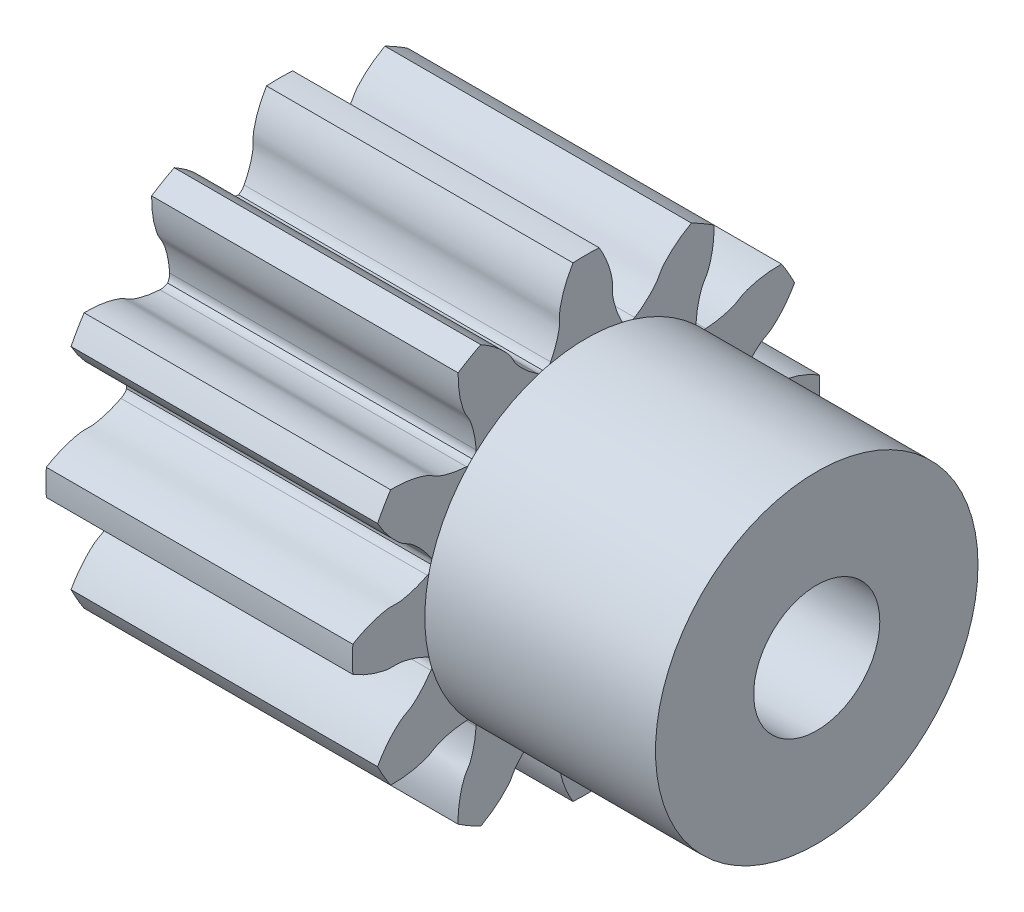
from build123d import *

# Parameters (mm, degrees)
SKETCH2_R      = 1.5
EXTRUDE1_DEPTH = 7.2898
SKETCH3_R      = 3.8354
SKETCH3_R_2    = 1.5
EXTRUDE2_DEPTH = 5.4864


with BuildPart() as part:
    # Sketch2 → Extrude1 (new body)
    with BuildSketch(Plane(origin=(0, 0, 0), x_dir=(0, 0, -1), z_dir=(1, 0, 0))):
        with BuildLine():
            ThreePointArc((-2.663120489, -2.663120489), (-2.750995667, -2.62511387), (-2.84628134, -2.615776294))
            add(Edge.make_bspline(
                [(-4.648816404, -3.043093837), (-4.614073522, -3.04349562), (-4.544568705, -3.043210814), (-4.440389461, -3.03921779), (-4.33642338, -3.031358347), (-4.232893645, -3.01896386), (-4.130045907, -3.001804641), (-4.028117704, -2.979814706), (-3.927423519, -2.952725802), (-3.827984631, -2.92152287), (-3.731196978, -2.881880043), (-3.642376214, -2.827118867), (-3.553555449, -2.772357691), (-3.456767797, -2.732714864), (-3.357328909, -2.701511932), (-3.256634724, -2.674423028), (-3.154706521, -2.652433093), (-3.051858782, -2.635273874), (-2.948976716, -2.622956925), (-2.880319624, -2.6177384), (-2.84628134, -2.615776294)],
                knots=[0.009804155, 0.009804155, 0.009804155, 0.009804155, 0.064334183, 0.118864103, 0.173393087, 0.227921379, 0.282449292, 0.336977028, 0.391504536, 0.446030976, 0.500535771, 0.555042104, 0.609548437, 0.664053231, 0.718579671, 0.773107179, 0.827634915, 0.882162828, 0.93669112, 0.990196737, 0.990196737, 0.990196737, 0.990196737], degree=3, weights=[1, 1, 1, 1, 1, 1, 1, 1, 1, 1, 1, 1, 1, 1, 1, 1, 1, 1, 1, 1, 1]))
            ThreePointArc((-4.648816404, -3.043093837), (-4.81185365, -2.778125), (-4.959804771, -2.504446185))
            add(Edge.make_bspline(
                [(-3.688469392, -1.1570638), (-3.707187767, -1.185560765), (-3.746035688, -1.242410288), (-3.808143512, -1.325350297), (-3.8744277, -1.405839442), (-3.944435644, -1.483116888), (-4.018242417, -1.556776158), (-4.094984392, -1.627291295), (-4.177709914, -1.691290447), (-4.269544865, -1.740830898), (-4.361379817, -1.790371348), (-4.444105339, -1.8543705), (-4.520847314, -1.924885638), (-4.594654086, -1.998544908), (-4.66466203, -2.075822354), (-4.730946218, -2.156311498), (-4.793445026, -2.239773635), (-4.852234544, -2.325881181), (-4.907782226, -2.414106541), (-4.942781284, -2.474157075), (-4.959804771, -2.504446185)],
                knots=[0.009803389, 0.009803389, 0.009803389, 0.009803389, 0.063309017, 0.117837321, 0.172365245, 0.226892992, 0.281420511, 0.335946963, 0.390451768, 0.444958113, 0.499464457, 0.553969263, 0.608495715, 0.663023233, 0.717550981, 0.772078905, 0.826607208, 0.881136204, 0.935666135, 0.990196174, 0.990196174, 0.990196174, 0.990196174], degree=3, weights=[1, 1, 1, 1, 1, 1, 1, 1, 1, 1, 1, 1, 1, 1, 1, 1, 1, 1, 1, 1, 1]))
            ThreePointArc((-3.688469392, -1.1570638), (-3.648913133, -1.069875198), (-3.637890241, -0.974769752))
            ThreePointArc((-3.637890241, -0.974769752), (-3.694989068, -0.897917466), (-3.772840094, -0.842188051))
            add(Edge.make_bspline(
                [(-5.547540022, -0.310988367), (-5.517652695, -0.328707763), (-5.457317354, -0.363213521), (-5.365098971, -0.411845083), (-5.271131982, -0.457021646), (-5.175275358, -0.498052573), (-5.077626995, -0.534616123), (-4.978359614, -0.566536382), (-4.877611439, -0.593423795), (-4.775893371, -0.616120708), (-4.672251391, -0.630182838), (-4.567949765, -0.627168651), (-4.463648138, -0.624154464), (-4.360006159, -0.638216595), (-4.25828809, -0.660913508), (-4.157539915, -0.687800921), (-4.058272535, -0.71972118), (-3.960624171, -0.75628473), (-3.865367214, -0.797058973), (-3.803299165, -0.826868143), (-3.772840094, -0.842188051)],
                knots=[0.009804155, 0.009804155, 0.009804155, 0.009804155, 0.064334183, 0.118864103, 0.173393087, 0.227921379, 0.282449292, 0.336977028, 0.391504536, 0.446030976, 0.500535771, 0.555042104, 0.609548437, 0.664053231, 0.718579671, 0.773107179, 0.827634915, 0.882162828, 0.93669112, 0.990196737, 0.990196737, 0.990196737, 0.990196737], degree=3, weights=[1, 1, 1, 1, 1, 1, 1, 1, 1, 1, 1, 1, 1, 1, 1, 1, 1, 1, 1, 1, 1]))
            ThreePointArc((-5.547540022, -0.310988367), (-5.55625, 0), (-5.547540022, 0.310988367))
            add(Edge.make_bspline(
                [(-3.772840094, 0.842188051), (-3.803299165, 0.826868143), (-3.865367214, 0.797058973), (-3.960624171, 0.75628473), (-4.058272535, 0.71972118), (-4.157539915, 0.687800921), (-4.25828809, 0.660913508), (-4.360006159, 0.638216595), (-4.463648138, 0.624154464), (-4.567949765, 0.627168651), (-4.672251391, 0.630182838), (-4.775893371, 0.616120708), (-4.877611439, 0.593423795), (-4.978359614, 0.566536382), (-5.077626995, 0.534616123), (-5.175275358, 0.498052573), (-5.271131982, 0.457021646), (-5.365098971, 0.411845083), (-5.457317354, 0.363213521), (-5.517652695, 0.328707763), (-5.547540022, 0.310988367)],
                knots=[0.009803389, 0.009803389, 0.009803389, 0.009803389, 0.063309017, 0.117837321, 0.172365245, 0.226892992, 0.281420511, 0.335946963, 0.390451768, 0.444958113, 0.499464457, 0.553969263, 0.608495715, 0.663023233, 0.717550981, 0.772078905, 0.826607208, 0.881136204, 0.935666135, 0.990196174, 0.990196174, 0.990196174, 0.990196174], degree=3, weights=[1, 1, 1, 1, 1, 1, 1, 1, 1, 1, 1, 1, 1, 1, 1, 1, 1, 1, 1, 1, 1]))
            ThreePointArc((-3.772840094, 0.842188051), (-3.694989068, 0.897917466), (-3.637890241, 0.974769752))
            ThreePointArc((-3.637890241, 0.974769752), (-3.648913133, 1.069875198), (-3.688469392, 1.1570638))
            add(Edge.make_bspline(
                [(-4.959804771, 2.504446185), (-4.942781284, 2.474157075), (-4.907782226, 2.414106541), (-4.852234544, 2.325881181), (-4.793445026, 2.239773635), (-4.730946218, 2.156311498), (-4.66466203, 2.075822354), (-4.594654086, 1.998544908), (-4.520847314, 1.924885638), (-4.444105339, 1.8543705), (-4.361379817, 1.790371348), (-4.269544865, 1.740830898), (-4.177709914, 1.691290447), (-4.094984392, 1.627291295), (-4.018242417, 1.556776158), (-3.944435644, 1.483116888), (-3.8744277, 1.405839442), (-3.808143512, 1.325350297), (-3.746035688, 1.242410288), (-3.707187767, 1.185560765), (-3.688469392, 1.1570638)],
                knots=[0.009804155, 0.009804155, 0.009804155, 0.009804155, 0.064334183, 0.118864103, 0.173393087, 0.227921379, 0.282449292, 0.336977028, 0.391504536, 0.446030976, 0.500535771, 0.555042104, 0.609548437, 0.664053231, 0.718579671, 0.773107179, 0.827634915, 0.882162828, 0.93669112, 0.990196737, 0.990196737, 0.990196737, 0.990196737], degree=3, weights=[1, 1, 1, 1, 1, 1, 1, 1, 1, 1, 1, 1, 1, 1, 1, 1, 1, 1, 1, 1, 1]))
            ThreePointArc((-4.959804771, 2.504446185), (-4.81185365, 2.778125), (-4.648816404, 3.043093837))
            add(Edge.make_bspline(
                [(-2.84628134, 2.615776294), (-2.880319624, 2.6177384), (-2.948976716, 2.622956925), (-3.051858782, 2.635273874), (-3.154706521, 2.652433093), (-3.256634724, 2.674423028), (-3.357328909, 2.701511932), (-3.456767797, 2.732714864), (-3.553555449, 2.772357691), (-3.642376214, 2.827118867), (-3.731196978, 2.881880043), (-3.827984631, 2.92152287), (-3.927423519, 2.952725802), (-4.028117704, 2.979814706), (-4.130045907, 3.001804641), (-4.232893645, 3.01896386), (-4.33642338, 3.031358347), (-4.440389461, 3.03921779), (-4.544568705, 3.043210814), (-4.614073522, 3.04349562), (-4.648816404, 3.043093837)],
                knots=[0.009803389, 0.009803389, 0.009803389, 0.009803389, 0.063309017, 0.117837321, 0.172365245, 0.226892992, 0.281420511, 0.335946963, 0.390451768, 0.444958113, 0.499464457, 0.553969263, 0.608495715, 0.663023233, 0.717550981, 0.772078905, 0.826607208, 0.881136204, 0.935666135, 0.990196174, 0.990196174, 0.990196174, 0.990196174], degree=3, weights=[1, 1, 1, 1, 1, 1, 1, 1, 1, 1, 1, 1, 1, 1, 1, 1, 1, 1, 1, 1, 1]))
            ThreePointArc((-2.84628134, 2.615776294), (-2.750995667, 2.62511387), (-2.663120489, 2.663120489))
            ThreePointArc((-2.663120489, 2.663120489), (-2.62511387, 2.750995667), (-2.615776294, 2.84628134))
            add(Edge.make_bspline(
                [(-3.043093837, 4.648816404), (-3.04349562, 4.614073522), (-3.043210814, 4.544568705), (-3.03921779, 4.440389461), (-3.031358347, 4.33642338), (-3.01896386, 4.232893645), (-3.001804641, 4.130045907), (-2.979814706, 4.028117704), (-2.952725802, 3.927423519), (-2.92152287, 3.827984631), (-2.881880043, 3.731196978), (-2.827118867, 3.642376214), (-2.772357691, 3.553555449), (-2.732714864, 3.456767797), (-2.701511932, 3.357328909), (-2.674423028, 3.256634724), (-2.652433093, 3.154706521), (-2.635273874, 3.051858782), (-2.622956925, 2.948976716), (-2.6177384, 2.880319624), (-2.615776294, 2.84628134)],
                knots=[0.009804155, 0.009804155, 0.009804155, 0.009804155, 0.064334183, 0.118864103, 0.173393087, 0.227921379, 0.282449292, 0.336977028, 0.391504536, 0.446030976, 0.500535771, 0.555042104, 0.609548437, 0.664053231, 0.718579671, 0.773107179, 0.827634915, 0.882162828, 0.93669112, 0.990196737, 0.990196737, 0.990196737, 0.990196737], degree=3, weights=[1, 1, 1, 1, 1, 1, 1, 1, 1, 1, 1, 1, 1, 1, 1, 1, 1, 1, 1, 1, 1]))
            ThreePointArc((-3.043093837, 4.648816404), (-2.778125, 4.81185365), (-2.504446185, 4.959804771))
            add(Edge.make_bspline(
                [(-1.1570638, 3.688469392), (-1.185560765, 3.707187767), (-1.242410288, 3.746035688), (-1.325350297, 3.808143512), (-1.405839442, 3.8744277), (-1.483116888, 3.944435644), (-1.556776158, 4.018242417), (-1.627291295, 4.094984392), (-1.691290447, 4.177709914), (-1.740830898, 4.269544865), (-1.790371348, 4.361379817), (-1.8543705, 4.444105339), (-1.924885638, 4.520847314), (-1.998544908, 4.594654086), (-2.075822354, 4.66466203), (-2.156311498, 4.730946218), (-2.239773635, 4.793445026), (-2.325881181, 4.852234544), (-2.414106541, 4.907782226), (-2.474157075, 4.942781284), (-2.504446185, 4.959804771)],
                knots=[0.009803389, 0.009803389, 0.009803389, 0.009803389, 0.063309017, 0.117837321, 0.172365245, 0.226892992, 0.281420511, 0.335946963, 0.390451768, 0.444958113, 0.499464457, 0.553969263, 0.608495715, 0.663023233, 0.717550981, 0.772078905, 0.826607208, 0.881136204, 0.935666135, 0.990196174, 0.990196174, 0.990196174, 0.990196174], degree=3, weights=[1, 1, 1, 1, 1, 1, 1, 1, 1, 1, 1, 1, 1, 1, 1, 1, 1, 1, 1, 1, 1]))
            ThreePointArc((-1.1570638, 3.688469392), (-1.069875198, 3.648913133), (-0.974769752, 3.637890241))
            ThreePointArc((-0.974769752, 3.637890241), (-0.897917466, 3.694989068), (-0.842188051, 3.772840094))
            add(Edge.make_bspline(
                [(-0.310988367, 5.547540022), (-0.328707763, 5.517652695), (-0.363213521, 5.457317354), (-0.411845083, 5.365098971), (-0.457021646, 5.271131982), (-0.498052573, 5.175275358), (-0.534616123, 5.077626995), (-0.566536382, 4.978359614), (-0.593423795, 4.877611439), (-0.616120708, 4.775893371), (-0.630182838, 4.672251391), (-0.627168651, 4.567949765), (-0.624154464, 4.463648138), (-0.638216595, 4.360006159), (-0.660913508, 4.25828809), (-0.687800921, 4.157539915), (-0.71972118, 4.058272535), (-0.75628473, 3.960624171), (-0.797058973, 3.865367214), (-0.826868143, 3.803299165), (-0.842188051, 3.772840094)],
                knots=[0.009804155, 0.009804155, 0.009804155, 0.009804155, 0.064334183, 0.118864103, 0.173393087, 0.227921379, 0.282449292, 0.336977028, 0.391504536, 0.446030976, 0.500535771, 0.555042104, 0.609548437, 0.664053231, 0.718579671, 0.773107179, 0.827634915, 0.882162828, 0.93669112, 0.990196737, 0.990196737, 0.990196737, 0.990196737], degree=3, weights=[1, 1, 1, 1, 1, 1, 1, 1, 1, 1, 1, 1, 1, 1, 1, 1, 1, 1, 1, 1, 1]))
            ThreePointArc((-0.310988367, 5.547540022), (0, 5.55625), (0.310988367, 5.547540022))
            add(Edge.make_bspline(
                [(0.842188051, 3.772840094), (0.826868143, 3.803299165), (0.797058973, 3.865367214), (0.75628473, 3.960624171), (0.71972118, 4.058272535), (0.687800921, 4.157539915), (0.660913508, 4.25828809), (0.638216595, 4.360006159), (0.624154464, 4.463648138), (0.627168651, 4.567949765), (0.630182838, 4.672251391), (0.616120708, 4.775893371), (0.593423795, 4.877611439), (0.566536382, 4.978359614), (0.534616123, 5.077626995), (0.498052573, 5.175275358), (0.457021646, 5.271131982), (0.411845083, 5.365098971), (0.363213521, 5.457317354), (0.328707763, 5.517652695), (0.310988367, 5.547540022)],
                knots=[0.009803389, 0.009803389, 0.009803389, 0.009803389, 0.063309017, 0.117837321, 0.172365245, 0.226892992, 0.281420511, 0.335946963, 0.390451768, 0.444958113, 0.499464457, 0.553969263, 0.608495715, 0.663023233, 0.717550981, 0.772078905, 0.826607208, 0.881136204, 0.935666135, 0.990196174, 0.990196174, 0.990196174, 0.990196174], degree=3, weights=[1, 1, 1, 1, 1, 1, 1, 1, 1, 1, 1, 1, 1, 1, 1, 1, 1, 1, 1, 1, 1]))
            ThreePointArc((0.842188051, 3.772840094), (0.897917466, 3.694989068), (0.974769752, 3.637890241))
            ThreePointArc((0.974769752, 3.637890241), (1.069875198, 3.648913133), (1.1570638, 3.688469392))
            add(Edge.make_bspline(
                [(2.504446185, 4.959804771), (2.474157075, 4.942781284), (2.414106541, 4.907782226), (2.325881181, 4.852234544), (2.239773635, 4.793445026), (2.156311498, 4.730946218), (2.075822354, 4.66466203), (1.998544908, 4.594654086), (1.924885638, 4.520847314), (1.8543705, 4.444105339), (1.790371348, 4.361379817), (1.740830898, 4.269544865), (1.691290447, 4.177709914), (1.627291295, 4.094984392), (1.556776158, 4.018242417), (1.483116888, 3.944435644), (1.405839442, 3.8744277), (1.325350297, 3.808143512), (1.242410288, 3.746035688), (1.185560765, 3.707187767), (1.1570638, 3.688469392)],
                knots=[0.009804155, 0.009804155, 0.009804155, 0.009804155, 0.064334183, 0.118864103, 0.173393087, 0.227921379, 0.282449292, 0.336977028, 0.391504536, 0.446030976, 0.500535771, 0.555042104, 0.609548437, 0.664053231, 0.718579671, 0.773107179, 0.827634915, 0.882162828, 0.93669112, 0.990196737, 0.990196737, 0.990196737, 0.990196737], degree=3, weights=[1, 1, 1, 1, 1, 1, 1, 1, 1, 1, 1, 1, 1, 1, 1, 1, 1, 1, 1, 1, 1]))
            ThreePointArc((2.504446185, 4.959804771), (2.778125, 4.81185365), (3.043093837, 4.648816404))
            add(Edge.make_bspline(
                [(2.615776294, 2.84628134), (2.6177384, 2.880319624), (2.622956925, 2.948976716), (2.635273874, 3.051858782), (2.652433093, 3.154706521), (2.674423028, 3.256634724), (2.701511932, 3.357328909), (2.732714864, 3.456767797), (2.772357691, 3.553555449), (2.827118867, 3.642376214), (2.881880043, 3.731196978), (2.92152287, 3.827984631), (2.952725802, 3.927423519), (2.979814706, 4.028117704), (3.001804641, 4.130045907), (3.01896386, 4.232893645), (3.031358347, 4.33642338), (3.03921779, 4.440389461), (3.043210814, 4.544568705), (3.04349562, 4.614073522), (3.043093837, 4.648816404)],
                knots=[0.009803389, 0.009803389, 0.009803389, 0.009803389, 0.063309017, 0.117837321, 0.172365245, 0.226892992, 0.281420511, 0.335946963, 0.390451768, 0.444958113, 0.499464457, 0.553969263, 0.608495715, 0.663023233, 0.717550981, 0.772078905, 0.826607208, 0.881136204, 0.935666135, 0.990196174, 0.990196174, 0.990196174, 0.990196174], degree=3, weights=[1, 1, 1, 1, 1, 1, 1, 1, 1, 1, 1, 1, 1, 1, 1, 1, 1, 1, 1, 1, 1]))
            ThreePointArc((2.615776294, 2.84628134), (2.62511387, 2.750995667), (2.663120489, 2.663120489))
            ThreePointArc((2.663120489, 2.663120489), (2.750995667, 2.62511387), (2.84628134, 2.615776294))
            add(Edge.make_bspline(
                [(4.648816404, 3.043093837), (4.614073522, 3.04349562), (4.544568705, 3.043210814), (4.440389461, 3.03921779), (4.33642338, 3.031358347), (4.232893645, 3.01896386), (4.130045907, 3.001804641), (4.028117704, 2.979814706), (3.927423519, 2.952725802), (3.827984631, 2.92152287), (3.731196978, 2.881880043), (3.642376214, 2.827118867), (3.553555449, 2.772357691), (3.456767797, 2.732714864), (3.357328909, 2.701511932), (3.256634724, 2.674423028), (3.154706521, 2.652433093), (3.051858782, 2.635273874), (2.948976716, 2.622956925), (2.880319624, 2.6177384), (2.84628134, 2.615776294)],
                knots=[0.009804155, 0.009804155, 0.009804155, 0.009804155, 0.064334183, 0.118864103, 0.173393087, 0.227921379, 0.282449292, 0.336977028, 0.391504536, 0.446030976, 0.500535771, 0.555042104, 0.609548437, 0.664053231, 0.718579671, 0.773107179, 0.827634915, 0.882162828, 0.93669112, 0.990196737, 0.990196737, 0.990196737, 0.990196737], degree=3, weights=[1, 1, 1, 1, 1, 1, 1, 1, 1, 1, 1, 1, 1, 1, 1, 1, 1, 1, 1, 1, 1]))
            ThreePointArc((4.648816404, 3.043093837), (4.81185365, 2.778125), (4.959804771, 2.504446185))
            add(Edge.make_bspline(
                [(3.688469392, 1.1570638), (3.707187767, 1.185560765), (3.746035688, 1.242410288), (3.808143512, 1.325350297), (3.8744277, 1.405839442), (3.944435644, 1.483116888), (4.018242417, 1.556776158), (4.094984392, 1.627291295), (4.177709914, 1.691290447), (4.269544865, 1.740830898), (4.361379817, 1.790371348), (4.444105339, 1.8543705), (4.520847314, 1.924885638), (4.594654086, 1.998544908), (4.66466203, 2.075822354), (4.730946218, 2.156311498), (4.793445026, 2.239773635), (4.852234544, 2.325881181), (4.907782226, 2.414106541), (4.942781284, 2.474157075), (4.959804771, 2.504446185)],
                knots=[0.009803389, 0.009803389, 0.009803389, 0.009803389, 0.063309017, 0.117837321, 0.172365245, 0.226892992, 0.281420511, 0.335946963, 0.390451768, 0.444958113, 0.499464457, 0.553969263, 0.608495715, 0.663023233, 0.717550981, 0.772078905, 0.826607208, 0.881136204, 0.935666135, 0.990196174, 0.990196174, 0.990196174, 0.990196174], degree=3, weights=[1, 1, 1, 1, 1, 1, 1, 1, 1, 1, 1, 1, 1, 1, 1, 1, 1, 1, 1, 1, 1]))
            ThreePointArc((3.688469392, 1.1570638), (3.648913133, 1.069875198), (3.637890241, 0.974769752))
            ThreePointArc((3.637890241, 0.974769752), (3.694989068, 0.897917466), (3.772840094, 0.842188051))
            add(Edge.make_bspline(
                [(5.547540022, 0.310988367), (5.517652695, 0.328707763), (5.457317354, 0.363213521), (5.365098971, 0.411845083), (5.271131982, 0.457021646), (5.175275358, 0.498052573), (5.077626995, 0.534616123), (4.978359614, 0.566536382), (4.877611439, 0.593423795), (4.775893371, 0.616120708), (4.672251391, 0.630182838), (4.567949765, 0.627168651), (4.463648138, 0.624154464), (4.360006159, 0.638216595), (4.25828809, 0.660913508), (4.157539915, 0.687800921), (4.058272535, 0.71972118), (3.960624171, 0.75628473), (3.865367214, 0.797058973), (3.803299165, 0.826868143), (3.772840094, 0.842188051)],
                knots=[0.009804155, 0.009804155, 0.009804155, 0.009804155, 0.064334183, 0.118864103, 0.173393087, 0.227921379, 0.282449292, 0.336977028, 0.391504536, 0.446030976, 0.500535771, 0.555042104, 0.609548437, 0.664053231, 0.718579671, 0.773107179, 0.827634915, 0.882162828, 0.93669112, 0.990196737, 0.990196737, 0.990196737, 0.990196737], degree=3, weights=[1, 1, 1, 1, 1, 1, 1, 1, 1, 1, 1, 1, 1, 1, 1, 1, 1, 1, 1, 1, 1]))
            ThreePointArc((5.547540022, 0.310988367), (5.55625, 0), (5.547540022, -0.310988367))
            add(Edge.make_bspline(
                [(3.772840094, -0.842188051), (3.803299165, -0.826868143), (3.865367214, -0.797058973), (3.960624171, -0.75628473), (4.058272535, -0.71972118), (4.157539915, -0.687800921), (4.25828809, -0.660913508), (4.360006159, -0.638216595), (4.463648138, -0.624154464), (4.567949765, -0.627168651), (4.672251391, -0.630182838), (4.775893371, -0.616120708), (4.877611439, -0.593423795), (4.978359614, -0.566536382), (5.077626995, -0.534616123), (5.175275358, -0.498052573), (5.271131982, -0.457021646), (5.365098971, -0.411845083), (5.457317354, -0.363213521), (5.517652695, -0.328707763), (5.547540022, -0.310988367)],
                knots=[0.009803389, 0.009803389, 0.009803389, 0.009803389, 0.063309017, 0.117837321, 0.172365245, 0.226892992, 0.281420511, 0.335946963, 0.390451768, 0.444958113, 0.499464457, 0.553969263, 0.608495715, 0.663023233, 0.717550981, 0.772078905, 0.826607208, 0.881136204, 0.935666135, 0.990196174, 0.990196174, 0.990196174, 0.990196174], degree=3, weights=[1, 1, 1, 1, 1, 1, 1, 1, 1, 1, 1, 1, 1, 1, 1, 1, 1, 1, 1, 1, 1]))
            ThreePointArc((3.772840094, -0.842188051), (3.694989068, -0.897917466), (3.637890241, -0.974769752))
            ThreePointArc((3.637890241, -0.974769752), (3.648913133, -1.069875198), (3.688469392, -1.1570638))
            add(Edge.make_bspline(
                [(4.959804771, -2.504446185), (4.942781284, -2.474157075), (4.907782226, -2.414106541), (4.852234544, -2.325881181), (4.793445026, -2.239773635), (4.730946218, -2.156311498), (4.66466203, -2.075822354), (4.594654086, -1.998544908), (4.520847314, -1.924885638), (4.444105339, -1.8543705), (4.361379817, -1.790371348), (4.269544865, -1.740830898), (4.177709914, -1.691290447), (4.094984392, -1.627291295), (4.018242417, -1.556776158), (3.944435644, -1.483116888), (3.8744277, -1.405839442), (3.808143512, -1.325350297), (3.746035688, -1.242410288), (3.707187767, -1.185560765), (3.688469392, -1.1570638)],
                knots=[0.009804155, 0.009804155, 0.009804155, 0.009804155, 0.064334183, 0.118864103, 0.173393087, 0.227921379, 0.282449292, 0.336977028, 0.391504536, 0.446030976, 0.500535771, 0.555042104, 0.609548437, 0.664053231, 0.718579671, 0.773107179, 0.827634915, 0.882162828, 0.93669112, 0.990196737, 0.990196737, 0.990196737, 0.990196737], degree=3, weights=[1, 1, 1, 1, 1, 1, 1, 1, 1, 1, 1, 1, 1, 1, 1, 1, 1, 1, 1, 1, 1]))
            ThreePointArc((4.959804771, -2.504446185), (4.81185365, -2.778125), (4.648816404, -3.043093837))
            add(Edge.make_bspline(
                [(2.84628134, -2.615776294), (2.880319624, -2.6177384), (2.948976716, -2.622956925), (3.051858782, -2.635273874), (3.154706521, -2.652433093), (3.256634724, -2.674423028), (3.357328909, -2.701511932), (3.456767797, -2.732714864), (3.553555449, -2.772357691), (3.642376214, -2.827118867), (3.731196978, -2.881880043), (3.827984631, -2.92152287), (3.927423519, -2.952725802), (4.028117704, -2.979814706), (4.130045907, -3.001804641), (4.232893645, -3.01896386), (4.33642338, -3.031358347), (4.440389461, -3.03921779), (4.544568705, -3.043210814), (4.614073522, -3.04349562), (4.648816404, -3.043093837)],
                knots=[0.009803389, 0.009803389, 0.009803389, 0.009803389, 0.063309017, 0.117837321, 0.172365245, 0.226892992, 0.281420511, 0.335946963, 0.390451768, 0.444958113, 0.499464457, 0.553969263, 0.608495715, 0.663023233, 0.717550981, 0.772078905, 0.826607208, 0.881136204, 0.935666135, 0.990196174, 0.990196174, 0.990196174, 0.990196174], degree=3, weights=[1, 1, 1, 1, 1, 1, 1, 1, 1, 1, 1, 1, 1, 1, 1, 1, 1, 1, 1, 1, 1]))
            ThreePointArc((2.84628134, -2.615776294), (2.750995667, -2.62511387), (2.663120489, -2.663120489))
            ThreePointArc((2.663120489, -2.663120489), (2.62511387, -2.750995667), (2.615776294, -2.84628134))
            add(Edge.make_bspline(
                [(3.043093837, -4.648816404), (3.04349562, -4.614073522), (3.043210814, -4.544568705), (3.03921779, -4.440389461), (3.031358347, -4.33642338), (3.01896386, -4.232893645), (3.001804641, -4.130045907), (2.979814706, -4.028117704), (2.952725802, -3.927423519), (2.92152287, -3.827984631), (2.881880043, -3.731196978), (2.827118867, -3.642376214), (2.772357691, -3.553555449), (2.732714864, -3.456767797), (2.701511932, -3.357328909), (2.674423028, -3.256634724), (2.652433093, -3.154706521), (2.635273874, -3.051858782), (2.622956925, -2.948976716), (2.6177384, -2.880319624), (2.615776294, -2.84628134)],
                knots=[0.009804155, 0.009804155, 0.009804155, 0.009804155, 0.064334183, 0.118864103, 0.173393087, 0.227921379, 0.282449292, 0.336977028, 0.391504536, 0.446030976, 0.500535771, 0.555042104, 0.609548437, 0.664053231, 0.718579671, 0.773107179, 0.827634915, 0.882162828, 0.93669112, 0.990196737, 0.990196737, 0.990196737, 0.990196737], degree=3, weights=[1, 1, 1, 1, 1, 1, 1, 1, 1, 1, 1, 1, 1, 1, 1, 1, 1, 1, 1, 1, 1]))
            ThreePointArc((3.043093837, -4.648816404), (2.778125, -4.81185365), (2.504446185, -4.959804771))
            add(Edge.make_bspline(
                [(1.1570638, -3.688469392), (1.185560765, -3.707187767), (1.242410288, -3.746035688), (1.325350297, -3.808143512), (1.405839442, -3.8744277), (1.483116888, -3.944435644), (1.556776158, -4.018242417), (1.627291295, -4.094984392), (1.691290447, -4.177709914), (1.740830898, -4.269544865), (1.790371348, -4.361379817), (1.8543705, -4.444105339), (1.924885638, -4.520847314), (1.998544908, -4.594654086), (2.075822354, -4.66466203), (2.156311498, -4.730946218), (2.239773635, -4.793445026), (2.325881181, -4.852234544), (2.414106541, -4.907782226), (2.474157075, -4.942781284), (2.504446185, -4.959804771)],
                knots=[0.009803389, 0.009803389, 0.009803389, 0.009803389, 0.063309017, 0.117837321, 0.172365245, 0.226892992, 0.281420511, 0.335946963, 0.390451768, 0.444958113, 0.499464457, 0.553969263, 0.608495715, 0.663023233, 0.717550981, 0.772078905, 0.826607208, 0.881136204, 0.935666135, 0.990196174, 0.990196174, 0.990196174, 0.990196174], degree=3, weights=[1, 1, 1, 1, 1, 1, 1, 1, 1, 1, 1, 1, 1, 1, 1, 1, 1, 1, 1, 1, 1]))
            ThreePointArc((1.1570638, -3.688469392), (1.069875198, -3.648913133), (0.974769752, -3.637890241))
            ThreePointArc((0.974769752, -3.637890241), (0.897917466, -3.694989068), (0.842188051, -3.772840094))
            add(Edge.make_bspline(
                [(0.310988367, -5.547540022), (0.328707763, -5.517652695), (0.363213521, -5.457317354), (0.411845083, -5.365098971), (0.457021646, -5.271131982), (0.498052573, -5.175275358), (0.534616123, -5.077626995), (0.566536382, -4.978359614), (0.593423795, -4.877611439), (0.616120708, -4.775893371), (0.630182838, -4.672251391), (0.627168651, -4.567949765), (0.624154464, -4.463648138), (0.638216595, -4.360006159), (0.660913508, -4.25828809), (0.687800921, -4.157539915), (0.71972118, -4.058272535), (0.75628473, -3.960624171), (0.797058973, -3.865367214), (0.826868143, -3.803299165), (0.842188051, -3.772840094)],
                knots=[0.009804155, 0.009804155, 0.009804155, 0.009804155, 0.064334183, 0.118864103, 0.173393087, 0.227921379, 0.282449292, 0.336977028, 0.391504536, 0.446030976, 0.500535771, 0.555042104, 0.609548437, 0.664053231, 0.718579671, 0.773107179, 0.827634915, 0.882162828, 0.93669112, 0.990196737, 0.990196737, 0.990196737, 0.990196737], degree=3, weights=[1, 1, 1, 1, 1, 1, 1, 1, 1, 1, 1, 1, 1, 1, 1, 1, 1, 1, 1, 1, 1]))
            ThreePointArc((0.310988367, -5.547540022), (0, -5.55625), (-0.310988367, -5.547540022))
            add(Edge.make_bspline(
                [(-0.842188051, -3.772840094), (-0.826868143, -3.803299165), (-0.797058973, -3.865367214), (-0.75628473, -3.960624171), (-0.71972118, -4.058272535), (-0.687800921, -4.157539915), (-0.660913508, -4.25828809), (-0.638216595, -4.360006159), (-0.624154464, -4.463648138), (-0.627168651, -4.567949765), (-0.630182838, -4.672251391), (-0.616120708, -4.775893371), (-0.593423795, -4.877611439), (-0.566536382, -4.978359614), (-0.534616123, -5.077626995), (-0.498052573, -5.175275358), (-0.457021646, -5.271131982), (-0.411845083, -5.365098971), (-0.363213521, -5.457317354), (-0.328707763, -5.517652695), (-0.310988367, -5.547540022)],
                knots=[0.009803389, 0.009803389, 0.009803389, 0.009803389, 0.063309017, 0.117837321, 0.172365245, 0.226892992, 0.281420511, 0.335946963, 0.390451768, 0.444958113, 0.499464457, 0.553969263, 0.608495715, 0.663023233, 0.717550981, 0.772078905, 0.826607208, 0.881136204, 0.935666135, 0.990196174, 0.990196174, 0.990196174, 0.990196174], degree=3, weights=[1, 1, 1, 1, 1, 1, 1, 1, 1, 1, 1, 1, 1, 1, 1, 1, 1, 1, 1, 1, 1]))
            ThreePointArc((-0.842188051, -3.772840094), (-0.897917466, -3.694989068), (-0.974769752, -3.637890241))
            ThreePointArc((-0.974769752, -3.637890241), (-1.069875198, -3.648913133), (-1.1570638, -3.688469392))
            add(Edge.make_bspline(
                [(-2.504446185, -4.959804771), (-2.474157075, -4.942781284), (-2.414106541, -4.907782226), (-2.325881181, -4.852234544), (-2.239773635, -4.793445026), (-2.156311498, -4.730946218), (-2.075822354, -4.66466203), (-1.998544908, -4.594654086), (-1.924885638, -4.520847314), (-1.8543705, -4.444105339), (-1.790371348, -4.361379817), (-1.740830898, -4.269544865), (-1.691290447, -4.177709914), (-1.627291295, -4.094984392), (-1.556776158, -4.018242417), (-1.483116888, -3.944435644), (-1.405839442, -3.8744277), (-1.325350297, -3.808143512), (-1.242410288, -3.746035688), (-1.185560765, -3.707187767), (-1.1570638, -3.688469392)],
                knots=[0.009804155, 0.009804155, 0.009804155, 0.009804155, 0.064334183, 0.118864103, 0.173393087, 0.227921379, 0.282449292, 0.336977028, 0.391504536, 0.446030976, 0.500535771, 0.555042104, 0.609548437, 0.664053231, 0.718579671, 0.773107179, 0.827634915, 0.882162828, 0.93669112, 0.990196737, 0.990196737, 0.990196737, 0.990196737], degree=3, weights=[1, 1, 1, 1, 1, 1, 1, 1, 1, 1, 1, 1, 1, 1, 1, 1, 1, 1, 1, 1, 1]))
            ThreePointArc((-2.504446185, -4.959804771), (-2.778125, -4.81185365), (-3.043093837, -4.648816404))
            add(Edge.make_bspline(
                [(-2.615776294, -2.84628134), (-2.6177384, -2.880319624), (-2.622956925, -2.948976716), (-2.635273874, -3.051858782), (-2.652433093, -3.154706521), (-2.674423028, -3.256634724), (-2.701511932, -3.357328909), (-2.732714864, -3.456767797), (-2.772357691, -3.553555449), (-2.827118867, -3.642376214), (-2.881880043, -3.731196978), (-2.92152287, -3.827984631), (-2.952725802, -3.927423519), (-2.979814706, -4.028117704), (-3.001804641, -4.130045907), (-3.01896386, -4.232893645), (-3.031358347, -4.33642338), (-3.03921779, -4.440389461), (-3.043210814, -4.544568705), (-3.04349562, -4.614073522), (-3.043093837, -4.648816404)],
                knots=[0.009803389, 0.009803389, 0.009803389, 0.009803389, 0.063309017, 0.117837321, 0.172365245, 0.226892992, 0.281420511, 0.335946963, 0.390451768, 0.444958113, 0.499464457, 0.553969263, 0.608495715, 0.663023233, 0.717550981, 0.772078905, 0.826607208, 0.881136204, 0.935666135, 0.990196174, 0.990196174, 0.990196174, 0.990196174], degree=3, weights=[1, 1, 1, 1, 1, 1, 1, 1, 1, 1, 1, 1, 1, 1, 1, 1, 1, 1, 1, 1, 1]))
            ThreePointArc((-2.615776294, -2.84628134), (-2.62511387, -2.750995667), (-2.663120489, -2.663120489))
        make_face()
        Circle(SKETCH2_R, mode=Mode.SUBTRACT)
    extrude(amount=EXTRUDE1_DEPTH)

    # Sketch3 → Extrude2 (add)
    with BuildSketch(Plane(origin=(7.2898, 0, 0), x_dir=(0, 0, -1), z_dir=(1, 0, 0))):
        Circle(SKETCH3_R)
        Circle(SKETCH3_R_2, mode=Mode.SUBTRACT)
    extrude(amount=EXTRUDE2_DEPTH)


solid = part.part
